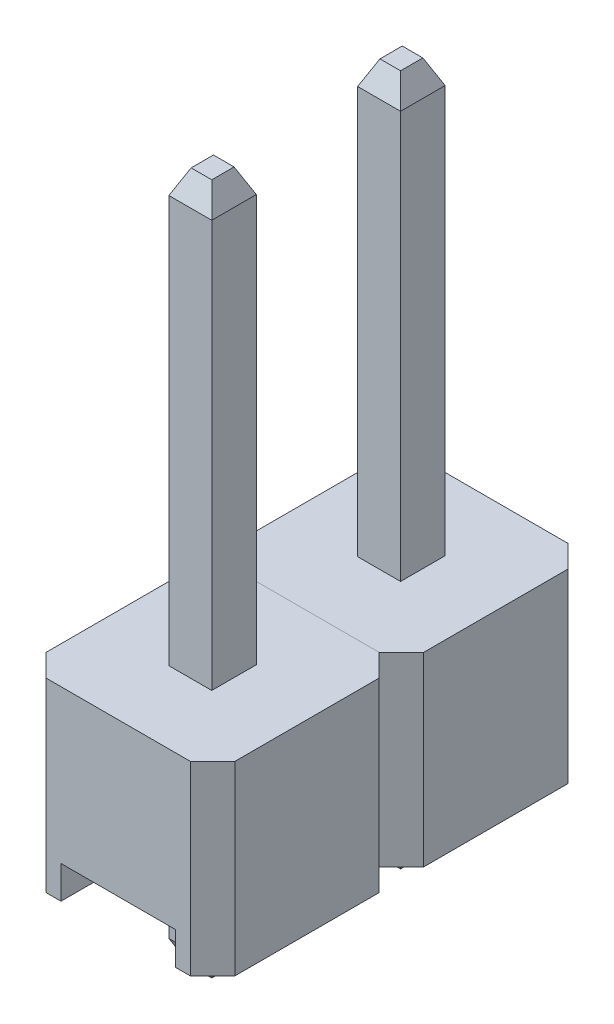
from build123d import *

# Parameters (mm, degrees)
CUERPO_PL_STICO_DEPTH = 2.5
CROQUIS2_W            = 1.54
CROQUIS2_H            = 2.54
RANURA_DEPTH          = 0.44
CROQUIS3_W            = 0.57750613
CROQUIS3_H            = 0.6
PIN_DEPTH             = 5.8
PIN_DEPTH_BACK        = 3.5
CHAFL_N1_SIZE         = 0.15
CHAFL_N1_SIZE2        = 0.321676038
CHAFL_N2_SIZE         = 0.15
CHAFL_N2_SIZE2        = 0.321676038
MATRIZ_COUNT          = 2
MATRIZ_PITCH          = 2.54


with BuildPart() as part:
    # Croquis1 → Cuerpo Plástico (new body)
    with BuildSketch(Plane(origin=(0, 0, 0), x_dir=(1, 0, 0), z_dir=(0, 1, 0))):
        Polygon((0.3, 0), (2.24, 0), (2.54, 0.3), (2.54, 2.24), (2.24, 2.54), (0.3, 2.54), (0, 2.24), (0, 0.3), align=None)
    extrude(amount=CUERPO_PL_STICO_DEPTH)

    # Croquis2 → Ranura (cut)
    with BuildSketch(Plane.XZ):
        with Locations((1.27, -1.27)):
            Rectangle(CROQUIS2_W, CROQUIS2_H)
    extrude(amount=-RANURA_DEPTH, mode=Mode.SUBTRACT)

    # Croquis3 → Pin (add, two sides)
    with BuildSketch(Plane(origin=(0, 2.5, 0), x_dir=(1, 0, 0), z_dir=(0, 1, 0))) as pin_sk:
        with Locations((1.27, 1.27)):
            Rectangle(CROQUIS3_W, CROQUIS3_H)
    extrude(amount=PIN_DEPTH)
    extrude(pin_sk.sketch, amount=-PIN_DEPTH_BACK)

    # Chaflán1
    chafl_n1_edges = [part.edges().sort_by_distance(p)[0] for p in [
        (0.981246935, 8.3, -1.27),
        (1.27, 8.3, -0.97),
        (1.558753065, 8.3, -1.27),
        (1.27, 8.3, -1.57),
    ]]
    chafl_n1_side = [part.faces().sort_by_distance(p)[0] for p in [
        (1.27, 8.3, -1.27),
    ]]
    chamfer(chafl_n1_edges, length=CHAFL_N1_SIZE, length2=CHAFL_N1_SIZE2, reference=chafl_n1_side[0])

    # Chaflán2
    chafl_n2_edges = [part.edges().sort_by_distance(p)[0] for p in [
        (0.981246935, -1, -1.27),
        (1.27, -1, -1.57),
        (1.558753065, -1, -1.27),
        (1.27, -1, -0.97),
    ]]
    chafl_n2_side = [part.faces().sort_by_distance(p)[0] for p in [
        (1.27, -1, -1.27),
    ]]
    chamfer(chafl_n2_edges, length=CHAFL_N2_SIZE, length2=CHAFL_N2_SIZE2, reference=chafl_n2_side[0])


with BuildPart() as matriz_1:
    # Matriz: pattern copy
    add(part.part.moved(Location(Vector(0, 0, 1) * (1 * MATRIZ_PITCH))))


solid = Compound([part.part, matriz_1.part])
